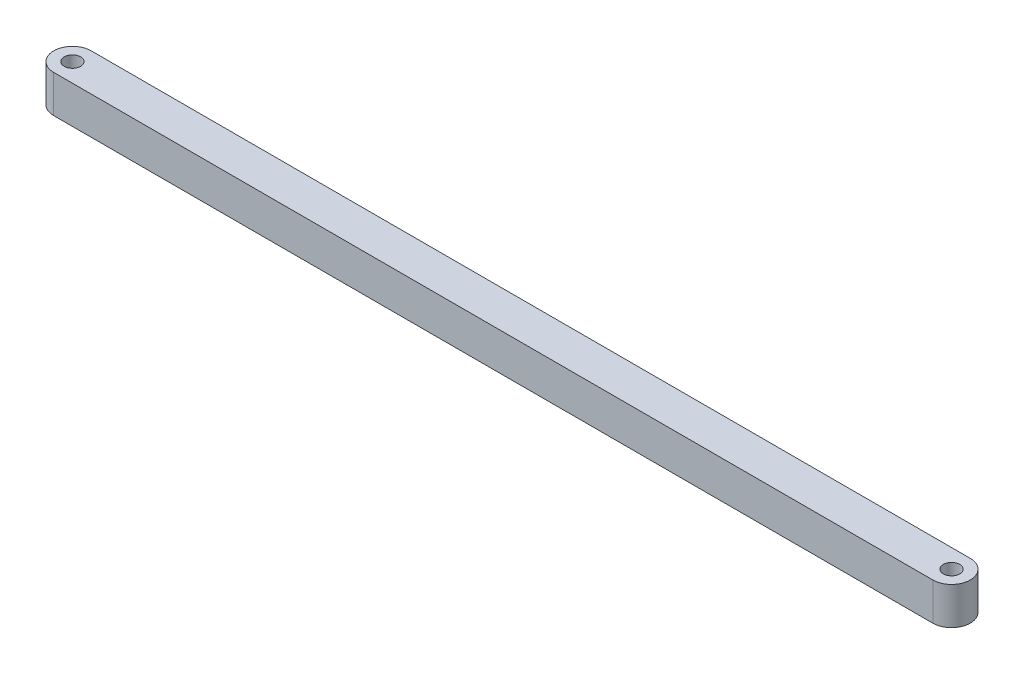
from build123d import *

# Parameters (mm, degrees)
SKETCH1_R           = 1.1
BOSS_EXTRUDE1_DEPTH = 5


with BuildPart() as part:
    # Sketch1 → Boss-Extrude1 (new body)
    with BuildSketch(Plane(origin=(0, 0, 0), x_dir=(1, 0, 0), z_dir=(0, 1, 0))):
        with BuildLine():
            Line((-58.7, 2.5), (58.7, 2.5))
            ThreePointArc((58.7, 2.5), (61.184816911, -0.007539789), (58.68482842, -2.499953964))
            Line((58.68482842, -2.499953964), (-58.7, -2.5))
            ThreePointArc((-58.7, -2.5), (-61.2, 0), (-58.7, 2.5))
        make_face()
        with Locations((-58.7, 0)):
            Circle(SKETCH1_R, mode=Mode.SUBTRACT)
        with Locations((58.68482842, 4.6036e-05)):
            Circle(SKETCH1_R, mode=Mode.SUBTRACT)
    extrude(amount=BOSS_EXTRUDE1_DEPTH)


solid = part.part
